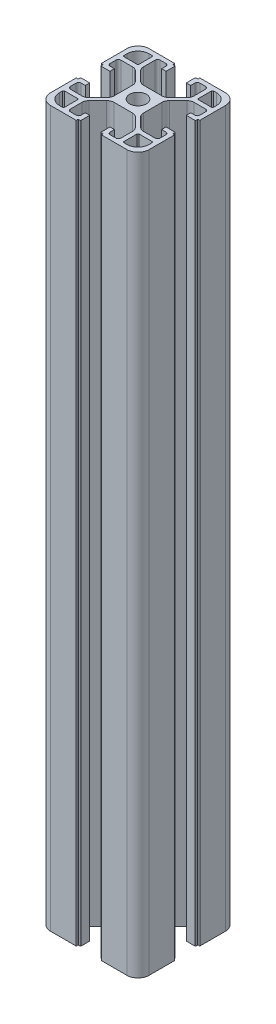
from build123d import *

# Parameters (mm, degrees)
BOSS_EXTRUDE1_DEPTH = 290.4


with BuildPart() as part:
    # Sketch1 → Boss-Extrude1 (new body)
    with BuildSketch(Plane(origin=(0, 0, 0), x_dir=(1, 0, 0), z_dir=(0, 1, 0))):
        with BuildLine():
            Line((84.170223908, 31.720417041), (84.170223908, 42.120417041))
            Line((84.170223908, 42.120417041), (83.570223908, 42.120417041))
            ThreePointArc((83.570223908, 42.120417041), (83.428802552, 42.178995685), (83.370223908, 42.320417041))
            Line((83.370223908, 42.320417041), (83.370223908, 42.920417041))
            ThreePointArc((83.370223908, 42.920417041), (83.311645264, 43.061838398), (83.170223908, 43.120417041))
            Line((83.170223908, 43.120417041), (79.670223908, 43.120417041))
            Line((79.670223908, 43.120417041), (79.670223908, 41.320417041))
            Line((79.670223908, 41.320417041), (81.370223908, 41.320417041))
            ThreePointArc((81.370223908, 41.320417041), (82.077330689, 41.027523823), (82.370223908, 40.320417041))
            Line((82.370223908, 40.320417041), (82.370223908, 37.970417041))
            ThreePointArc((82.370223908, 37.970417041), (82.077330689, 37.26331026), (81.370223908, 36.970417041))
            Line((81.370223908, 36.970417041), (76.723524767, 36.970417041))
            ThreePointArc((76.723524767, 36.970417041), (75.57547447, 37.198778444), (74.602204423, 37.849096698))
            Line((74.602204423, 37.849096698), (71.048903564, 41.402397557))
            ThreePointArc((71.048903564, 41.402397557), (70.39858531, 42.375667603), (70.170223908, 43.5237179))
            Line((70.170223908, 43.5237179), (70.170223908, 50.917116183))
            ThreePointArc((70.170223908, 50.917116183), (70.39858531, 52.06516648), (71.048903564, 53.038436526))
            Line((71.048903564, 53.038436526), (74.602204423, 56.591737385))
            ThreePointArc((74.602204423, 56.591737385), (75.57547447, 57.242055639), (76.723524767, 57.470417041))
            Line((76.723524767, 57.470417041), (81.370223908, 57.470417041))
            ThreePointArc((81.370223908, 57.470417041), (82.077330689, 57.177523823), (82.370223908, 56.470417041))
            Line((82.370223908, 56.470417041), (82.370223908, 54.120417041))
            ThreePointArc((82.370223908, 54.120417041), (82.077330689, 53.41331026), (81.370223908, 53.120417041))
            Line((81.370223908, 53.120417041), (79.670223908, 53.120417041))
            Line((79.670223908, 53.120417041), (79.670223908, 51.320417041))
            Line((79.670223908, 51.320417041), (83.170223908, 51.320417041))
            ThreePointArc((83.170223908, 51.320417041), (83.311645264, 51.378995685), (83.370223908, 51.520417041))
            Line((83.370223908, 51.520417041), (83.370223908, 52.120417041))
            ThreePointArc((83.370223908, 52.120417041), (83.428802552, 52.261838398), (83.570223908, 52.320417041))
            Line((83.570223908, 52.320417041), (84.170223908, 52.320417041))
            Line((84.170223908, 52.320417041), (84.170223908, 62.720417041))
            ThreePointArc((84.170223908, 62.720417041), (82.852204423, 65.902397557), (79.670223908, 67.220417041))
            Line((79.670223908, 67.220417041), (69.270223908, 67.220417041))
            Line((69.270223908, 67.220417041), (69.270223908, 66.420417041))
            Line((69.270223908, 66.420417041), (68.470223908, 66.420417041))
            ThreePointArc((68.470223908, 66.420417041), (68.328802552, 66.361838398), (68.270223908, 66.220417041))
            Line((68.270223908, 66.220417041), (68.270223908, 62.720417041))
            Line((68.270223908, 62.720417041), (70.070223908, 62.720417041))
            Line((70.070223908, 62.720417041), (70.070223908, 64.420417041))
            ThreePointArc((70.070223908, 64.420417041), (70.363117127, 65.127523823), (71.070223908, 65.420417041))
            Line((71.070223908, 65.420417041), (73.420223908, 65.420417041))
            ThreePointArc((73.420223908, 65.420417041), (74.127330689, 65.127523823), (74.420223908, 64.420417041))
            Line((74.420223908, 64.420417041), (74.420223908, 59.7737179))
            ThreePointArc((74.420223908, 59.7737179), (74.191862505, 58.625667603), (73.541544251, 57.652397557))
            Line((73.541544251, 57.652397557), (69.988243393, 54.099096698))
            ThreePointArc((69.988243393, 54.099096698), (69.014973346, 53.448778444), (67.866923049, 53.220417041))
            Line((67.866923049, 53.220417041), (60.473524767, 53.220417041))
            ThreePointArc((60.473524767, 53.220417041), (59.32547447, 53.448778444), (58.352204423, 54.099096698))
            Line((58.352204423, 54.099096698), (54.798903564, 57.652397557))
            ThreePointArc((54.798903564, 57.652397557), (54.14858531, 58.625667603), (53.920223908, 59.7737179))
            Line((53.920223908, 59.7737179), (53.920223908, 64.420417041))
            ThreePointArc((53.920223908, 64.420417041), (54.213117127, 65.127523823), (54.920223908, 65.420417041))
            Line((54.920223908, 65.420417041), (57.270223908, 65.420417041))
            ThreePointArc((57.270223908, 65.420417041), (57.977330689, 65.127523823), (58.270223908, 64.420417041))
            Line((58.270223908, 64.420417041), (58.270223908, 62.720417041))
            Line((58.270223908, 62.720417041), (60.070223908, 62.720417041))
            Line((60.070223908, 62.720417041), (60.070223908, 66.420417041))
            Line((60.070223908, 66.420417041), (59.270223908, 66.420417041))
            ThreePointArc((59.270223908, 66.420417041), (59.128802552, 66.478995685), (59.070223908, 66.620417041))
            Line((59.070223908, 66.620417041), (59.070223908, 67.220417041))
            Line((59.070223908, 67.220417041), (48.670223908, 67.220417041))
            ThreePointArc((48.670223908, 67.220417041), (45.488243393, 65.902397557), (44.170223908, 62.720417041))
            Line((44.170223908, 62.720417041), (44.170223908, 52.320417041))
            Line((44.170223908, 52.320417041), (44.770223908, 52.320417041))
            ThreePointArc((44.770223908, 52.320417041), (44.911645264, 52.261838398), (44.970223908, 52.120417041))
            Line((44.970223908, 52.120417041), (44.970223908, 51.520417041))
            ThreePointArc((44.970223908, 51.520417041), (45.028802552, 51.378995685), (45.170223908, 51.320417041))
            Line((45.170223908, 51.320417041), (48.670223908, 51.320417041))
            Line((48.670223908, 51.320417041), (48.670223908, 53.120417041))
            Line((48.670223908, 53.120417041), (46.970223908, 53.120417041))
            ThreePointArc((46.970223908, 53.120417041), (46.263117127, 53.41331026), (45.970223908, 54.120417041))
            Line((45.970223908, 54.120417041), (45.970223908, 56.470417041))
            ThreePointArc((45.970223908, 56.470417041), (46.263117127, 57.177523823), (46.970223908, 57.470417041))
            Line((46.970223908, 57.470417041), (51.616923049, 57.470417041))
            ThreePointArc((51.616923049, 57.470417041), (52.764973346, 57.242055639), (53.738243393, 56.591737385))
            Line((53.738243393, 56.591737385), (57.291544251, 53.038436526))
            ThreePointArc((57.291544251, 53.038436526), (57.941862505, 52.06516648), (58.170223908, 50.917116183))
            Line((58.170223908, 50.917116183), (58.170223908, 43.5237179))
            ThreePointArc((58.170223908, 43.5237179), (57.941862505, 42.375667603), (57.291544251, 41.402397557))
            Line((57.291544251, 41.402397557), (53.738243393, 37.849096698))
            ThreePointArc((53.738243393, 37.849096698), (52.764973346, 37.198778444), (51.616923049, 36.970417041))
            Line((51.616923049, 36.970417041), (46.970223908, 36.970417041))
            ThreePointArc((46.970223908, 36.970417041), (46.263117127, 37.26331026), (45.970223908, 37.970417041))
            Line((45.970223908, 37.970417041), (45.970223908, 40.320417041))
            ThreePointArc((45.970223908, 40.320417041), (46.263117127, 41.027523823), (46.970223908, 41.320417041))
            Line((46.970223908, 41.320417041), (48.670223908, 41.320417041))
            Line((48.670223908, 41.320417041), (48.670223908, 43.120417041))
            Line((48.670223908, 43.120417041), (45.170223908, 43.120417041))
            ThreePointArc((45.170223908, 43.120417041), (45.028802552, 43.061838398), (44.970223908, 42.920417041))
            Line((44.970223908, 42.920417041), (44.970223908, 42.320417041))
            ThreePointArc((44.970223908, 42.320417041), (44.911645264, 42.178995685), (44.770223908, 42.120417041))
            Line((44.770223908, 42.120417041), (44.170223908, 42.120417041))
            Line((44.170223908, 42.120417041), (44.170223908, 31.720417041))
            ThreePointArc((44.170223908, 31.720417041), (45.488243393, 28.538436526), (48.670223908, 27.220417041))
            Line((48.670223908, 27.220417041), (59.070223908, 27.220417041))
            Line((59.070223908, 27.220417041), (59.070223908, 27.820417041))
            ThreePointArc((59.070223908, 27.820417041), (59.128802552, 27.961838398), (59.270223908, 28.020417041))
            Line((59.270223908, 28.020417041), (59.870223908, 28.020417041))
            ThreePointArc((59.870223908, 28.020417041), (60.011645264, 28.078995685), (60.070223908, 28.220417041))
            Line((60.070223908, 28.220417041), (60.070223908, 31.720417041))
            Line((60.070223908, 31.720417041), (58.270223908, 31.720417041))
            Line((58.270223908, 31.720417041), (58.270223908, 30.020417041))
            ThreePointArc((58.270223908, 30.020417041), (57.977330689, 29.31331026), (57.270223908, 29.020417041))
            Line((57.270223908, 29.020417041), (54.920223908, 29.020417041))
            ThreePointArc((54.920223908, 29.020417041), (54.213117127, 29.31331026), (53.920223908, 30.020417041))
            Line((53.920223908, 30.020417041), (53.920223908, 34.667116183))
            ThreePointArc((53.920223908, 34.667116183), (54.14858531, 35.81516648), (54.798903564, 36.788436526))
            Line((54.798903564, 36.788436526), (58.352204423, 40.341737385))
            ThreePointArc((58.352204423, 40.341737385), (59.32547447, 40.992055639), (60.473524767, 41.220417041))
            Line((60.473524767, 41.220417041), (67.866923049, 41.220417041))
            ThreePointArc((67.866923049, 41.220417041), (69.014973346, 40.992055639), (69.988243393, 40.341737385))
            Line((69.988243393, 40.341737385), (73.541544251, 36.788436526))
            ThreePointArc((73.541544251, 36.788436526), (74.191862505, 35.81516648), (74.420223908, 34.667116183))
            Line((74.420223908, 34.667116183), (74.420223908, 30.020417041))
            ThreePointArc((74.420223908, 30.020417041), (74.127330689, 29.31331026), (73.420223908, 29.020417041))
            Line((73.420223908, 29.020417041), (71.070223908, 29.020417041))
            ThreePointArc((71.070223908, 29.020417041), (70.363117127, 29.31331026), (70.070223908, 30.020417041))
            Line((70.070223908, 30.020417041), (70.070223908, 31.720417041))
            Line((70.070223908, 31.720417041), (68.270223908, 31.720417041))
            Line((68.270223908, 31.720417041), (68.270223908, 28.220417041))
            ThreePointArc((68.270223908, 28.220417041), (68.328802552, 28.078995685), (68.470223908, 28.020417041))
            Line((68.470223908, 28.020417041), (69.070223908, 28.020417041))
            ThreePointArc((69.070223908, 28.020417041), (69.211645264, 27.961838398), (69.270223908, 27.820417041))
            Line((69.270223908, 27.820417041), (69.270223908, 27.220417041))
            Line((69.270223908, 27.220417041), (79.670223908, 27.220417041))
            ThreePointArc((79.670223908, 27.220417041), (82.852204423, 28.538436526), (84.170223908, 31.720417041))
        make_face()
        with BuildLine():
            Line((82.370223908, 34.670417041), (82.370223908, 33.520417041))
            ThreePointArc((82.370223908, 33.520417041), (81.052204423, 30.338436526), (77.870223908, 29.020417041))
            Line((77.870223908, 29.020417041), (76.720223908, 29.020417041))
            ThreePointArc((76.720223908, 29.020417041), (76.366670517, 29.166863651), (76.220223908, 29.520417041))
            Line((76.220223908, 29.520417041), (76.220223908, 34.670417041))
            ThreePointArc((76.220223908, 34.670417041), (76.366670517, 35.023970432), (76.720223908, 35.170417041))
            Line((76.720223908, 35.170417041), (81.870223908, 35.170417041))
            ThreePointArc((81.870223908, 35.170417041), (82.223777298, 35.023970432), (82.370223908, 34.670417041))
        make_face(mode=Mode.SUBTRACT)
        with BuildLine():
            Line((51.620223908, 29.020417041), (50.470223908, 29.020417041))
            ThreePointArc((50.470223908, 29.020417041), (47.288243393, 30.338436526), (45.970223908, 33.520417041))
            Line((45.970223908, 33.520417041), (45.970223908, 34.670417041))
            ThreePointArc((45.970223908, 34.670417041), (46.116670517, 35.023970432), (46.470223908, 35.170417041))
            Line((46.470223908, 35.170417041), (51.620223908, 35.170417041))
            ThreePointArc((51.620223908, 35.170417041), (51.973777298, 35.023970432), (52.120223908, 34.670417041))
            Line((52.120223908, 34.670417041), (52.120223908, 29.520417041))
            ThreePointArc((52.120223908, 29.520417041), (51.973777298, 29.166863651), (51.620223908, 29.020417041))
        make_face(mode=Mode.SUBTRACT)
        with BuildLine():
            Line((45.970223908, 59.770417041), (45.970223908, 60.920417041))
            ThreePointArc((45.970223908, 60.920417041), (47.288243393, 64.102397557), (50.470223908, 65.420417041))
            Line((50.470223908, 65.420417041), (51.620223908, 65.420417041))
            ThreePointArc((51.620223908, 65.420417041), (51.973777298, 65.273970432), (52.120223908, 64.920417041))
            Line((52.120223908, 64.920417041), (52.120223908, 59.770417041))
            ThreePointArc((52.120223908, 59.770417041), (51.973777298, 59.416863651), (51.620223908, 59.270417041))
            Line((51.620223908, 59.270417041), (46.470223908, 59.270417041))
            ThreePointArc((46.470223908, 59.270417041), (46.116670517, 59.416863651), (45.970223908, 59.770417041))
        make_face(mode=Mode.SUBTRACT)
        with BuildLine():
            Line((76.720223908, 65.420417041), (77.870223908, 65.420417041))
            ThreePointArc((77.870223908, 65.420417041), (81.052204423, 64.102397557), (82.370223908, 60.920417041))
            Line((82.370223908, 60.920417041), (82.370223908, 59.770417041))
            ThreePointArc((82.370223908, 59.770417041), (82.223777298, 59.416863651), (81.870223908, 59.270417041))
            Line((81.870223908, 59.270417041), (76.720223908, 59.270417041))
            ThreePointArc((76.720223908, 59.270417041), (76.366670517, 59.416863651), (76.220223908, 59.770417041))
            Line((76.220223908, 59.770417041), (76.220223908, 64.920417041))
            ThreePointArc((76.220223908, 64.920417041), (76.366670517, 65.273970432), (76.720223908, 65.420417041))
        make_face(mode=Mode.SUBTRACT)
        with BuildLine():
            ThreePointArc((60.770223908, 47.220417041), (64.170223908, 43.820417041), (67.570223908, 47.220417041))
            ThreePointArc((67.570223908, 47.220417041), (64.170223908, 50.620417041), (60.770223908, 47.220417041))
        make_face(mode=Mode.SUBTRACT)
    extrude(amount=BOSS_EXTRUDE1_DEPTH)


solid = part.part
